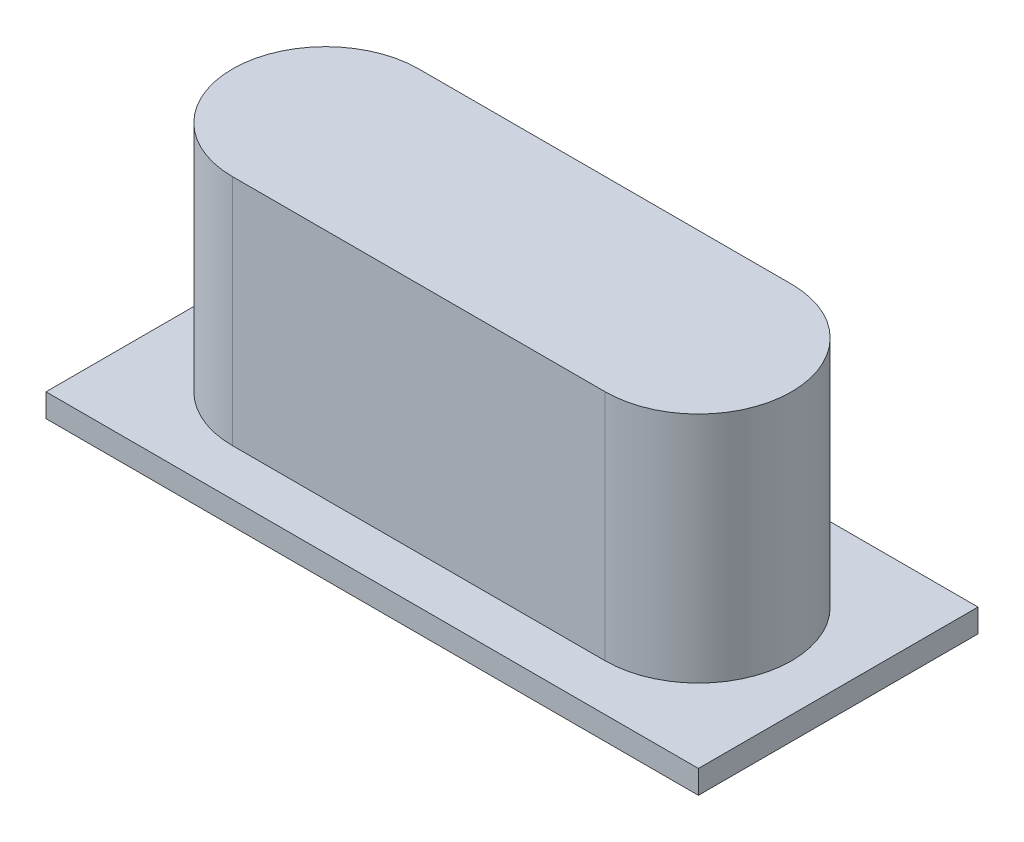
from build123d import *

# Parameters (mm, degrees)
SKETCH1_W           = 7
SKETCH1_H           = 3
BOSS_EXTRUDE1_DEPTH = 0.25
BOSS_EXTRUDE2_DEPTH = 2.5


with BuildPart() as part:
    # Sketch1 → Boss-Extrude1 (new body)
    with BuildSketch(Plane(origin=(0, 0, 0), x_dir=(1, 0, 0), z_dir=(0, 1, 0))):
        Rectangle(SKETCH1_W, SKETCH1_H)
    extrude(amount=BOSS_EXTRUDE1_DEPTH)

    # Sketch2 → Boss-Extrude2 (add)
    with BuildSketch(Plane(origin=(0, 0.25, 0), x_dir=(1, 0, 0), z_dir=(0, 1, 0))):
        with BuildLine():
            Line((2, -1), (-2, -1))
            ThreePointArc((-2, -1), (-3, 0), (-2, 1))
            Line((-2, 1), (2, 1))
            ThreePointArc((2, 1), (3, 0), (2, -1))
        make_face()
    extrude(amount=BOSS_EXTRUDE2_DEPTH)


solid = part.part
